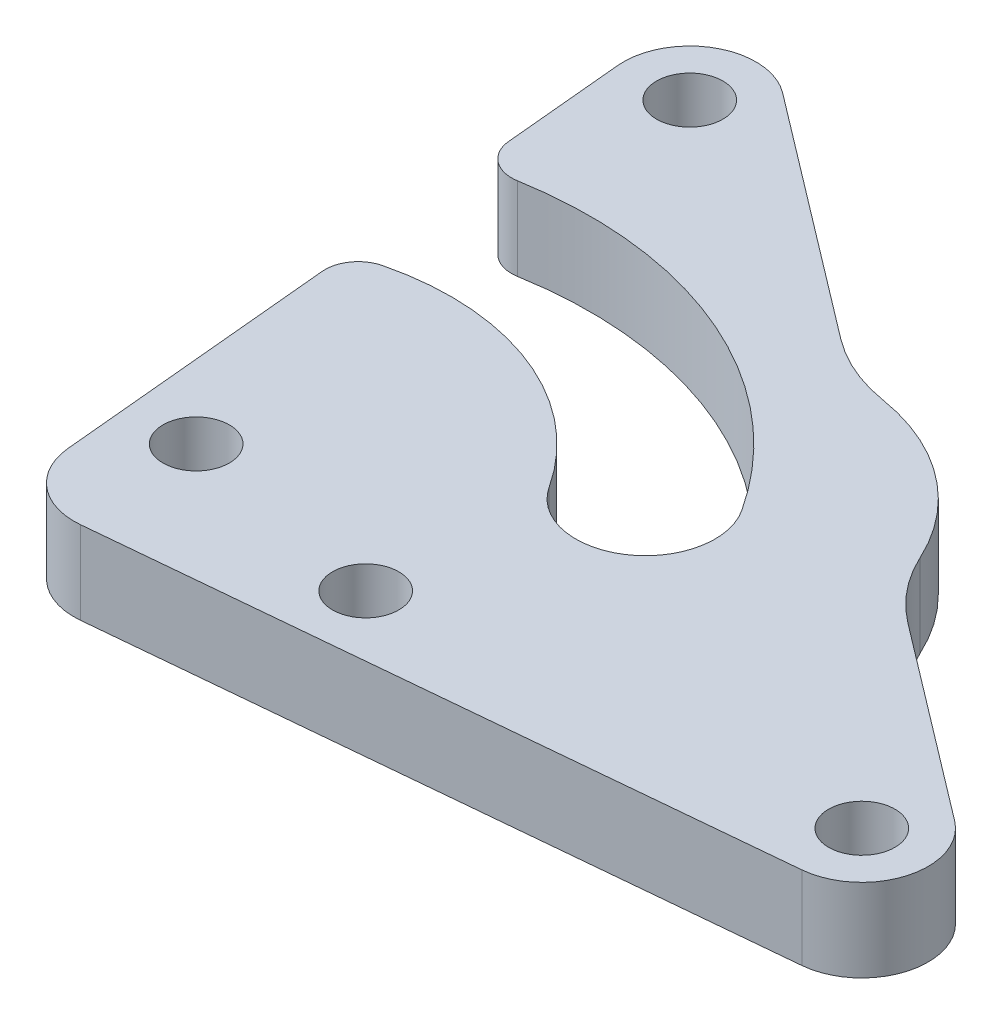
from build123d import *

# Parameters (mm, degrees)
SKETCH_1_R          = 2
EXTRUDE_1_DEPTH     = 5
EXTRUDE_2_DEPTH     = 5
CUT_EXTRUDE_1_DEPTH = 6
EXTRUDE_3_DEPTH     = 5
FILLET_1_R          = 10
FILLET_2_R          = 2
SKETCH_6_R          = 2
CUT_EXTRUDE_2_DEPTH = 6


with BuildPart() as part:
    # 草图1 → 凸台-拉伸1 (new body)
    with BuildSketch(Plane(origin=(0, 0, 0), x_dir=(1, 0, 0), z_dir=(0, 1, 0))):
        with BuildLine():
            ThreePointArc((-20.0875, 4), (-23.044826598, 2.693365811), (-24.070081176, -0.372890305))
            ThreePointArc((-24.070081176, -0.372890305), (-22.780865811, -2.957326598), (-20.0875, -4))
            ThreePointArc((-20.0875, -4), (-17.130173402, -2.693365811), (-16.104918824, 0.372890305))
            Line((-16.104918824, 0.372890305), (-16.444526225, 4))
            Line((-16.444526225, 4), (-20.0875, 4))
        make_face()
        with Locations((-20.0875, 0)):
            Circle(SKETCH_1_R, mode=Mode.SUBTRACT)
        with BuildLine():
            Line((-27.14754486, 32.495352138), (-24.070081176, -0.372890305))
            ThreePointArc((-24.070081176, -0.372890305), (-23.044826598, 2.693365811), (-20.0875, 4))
            Line((-20.0875, 4), (-16.444526225, 4))
            Line((-16.444526225, 4), (-18.333300994, 24.172685504))
            Line((-18.333300994, 24.172685504), (-25.585127327, 29.683464909))
            ThreePointArc((-25.585127327, 29.683464909), (-26.661456606, 30.925425609), (-27.14754486, 32.495352138))
        make_face()
        with BuildLine():
            ThreePointArc((-20.74480004, 36.053019976), (-25.107780517, 36.364735365), (-27.14754486, 32.495352138))
            ThreePointArc((-27.14754486, 32.495352138), (-26.661456606, 30.925425609), (-25.585127327, 29.683464909))
            Line((-25.585127327, 29.683464909), (-18.333300994, 24.172685504))
            Line((-18.333300994, 24.172685504), (-19.182382508, 33.241132747))
            ThreePointArc((-19.182382508, 33.241132747), (-19.668470762, 34.811059276), (-20.74480004, 36.053019976))
        make_face()
        with Locations((-23.164963684, 32.868242443)):
            Circle(SKETCH_1_R, mode=Mode.SUBTRACT)
        with BuildLine():
            Line((22.507663644, 3.184777534), (-20.74480004, 36.053019976))
            ThreePointArc((-20.74480004, 36.053019976), (-19.668470762, 34.811059276), (-19.182382508, 33.241132747))
            Line((-19.182382508, 33.241132747), (-18.333300994, 24.172685504))
            Line((-18.333300994, 24.172685504), (8.212637649, 4))
            Line((8.212637649, 4), (20.0875, 4))
            ThreePointArc((20.0875, 4), (21.364388771, 3.790719598), (22.507663644, 3.184777534))
        make_face()
        with BuildLine():
            ThreePointArc((-16.104918824, 0.372890305), (-17.130173402, -2.693365811), (-20.0875, -4))
            Line((-20.0875, -4), (20.0875, -4))
            ThreePointArc((20.0875, -4), (18.810611229, -3.790719598), (17.667336356, -3.184777534))
            Line((17.667336356, -3.184777534), (8.212637649, 4))
            Line((8.212637649, 4), (-16.444526225, 4))
            Line((-16.444526225, 4), (-16.104918824, 0.372890305))
        make_face()
        with BuildLine():
            ThreePointArc((17.667336356, -3.184777534), (18.810611229, -3.790719598), (20.0875, -4))
            ThreePointArc((20.0875, -4), (23.878219598, -1.276888771), (22.507663644, 3.184777534))
            ThreePointArc((22.507663644, 3.184777534), (21.364388771, 3.790719598), (20.0875, 4))
            Line((20.0875, 4), (8.212637649, 4))
            Line((8.212637649, 4), (17.667336356, -3.184777534))
        make_face()
        with Locations((20.0875, 0)):
            Circle(SKETCH_1_R, mode=Mode.SUBTRACT)
        Polygon((-18.333300994, 24.172685504), (-16.444526225, 4), (8.212637649, 4), align=None)
    extrude(amount=EXTRUDE_1_DEPTH)

    # 草图2 → 凸台-拉伸2 (add)
    with BuildSketch(Plane(origin=(0, 5, 0), x_dir=(1, 0, 0), z_dir=(0, 1, 0))):
        with BuildLine():
            ThreePointArc((-20.0875, -4), (-22.780865811, -2.957326598), (-24.070081176, -0.372890305))
            Line((-24.070081176, -0.372890305), (-23.720962628, -4.10158193))
            ThreePointArc((-23.720962628, -4.10158193), (-22.290826699, -6.808468121), (-19.365512753, -7.711274824))
            Line((-19.365512753, -7.711274824), (20.460368699, -3.982583199))
            ThreePointArc((20.460368699, -3.982583199), (20.274137625, -3.995643427), (20.0875, -4))
            Line((20.0875, -4), (-20.0875, -4))
        make_face()
    extrude(amount=-EXTRUDE_2_DEPTH)

    # 草图3 → 切除-拉伸1 (cut, through all)
    with BuildSketch(Plane(origin=(0, 5, 0), x_dir=(1, 0, 0), z_dir=(0, 1, 0))):
        with BuildLine():
            ThreePointArc((-36.289327432, 17.433897667), (-37.629570165, 14.285674695), (-36.182704661, 11.185007239))
            ThreePointArc((-36.182704661, 11.185007239), (-31.653466249, 15.823666602), (-25.858788976, 18.731049718))
            Line((-25.858788976, 18.731049718), (-26.257218708, 22.986399698))
            ThreePointArc((-26.257218708, 22.986399698), (-31.612650276, 20.82332613), (-36.289327432, 17.433897667))
        make_face()
        with BuildLine():
            ThreePointArc((-25.858788976, 18.731049718), (-11.47348363, 17.605644606), (-1.756724615, 6.938492183))
            ThreePointArc((-1.756724615, 6.938492183), (0.40025314, 9.594618202), (-0.134776474, 12.974159854))
            ThreePointArc((-0.134776474, 12.974159854), (-11.569633945, 22.223545124), (-26.257218708, 22.986399698))
            Line((-26.257218708, 22.986399698), (-25.858788976, 18.731049718))
        make_face()
        with BuildLine():
            ThreePointArc((-7.176914189, 8.395044611), (-4.745829362, 6.62850376), (-1.756724615, 6.938492183))
            ThreePointArc((-1.756724615, 6.938492183), (-11.47348363, 17.605644606), (-25.858788976, 18.731049718))
            Line((-25.858788976, 18.731049718), (-25.456435977, 14.433798061))
            ThreePointArc((-25.456435977, 14.433798061), (-15.256790284, 14.622730376), (-7.176914189, 8.395044611))
        make_face()
        with BuildLine():
            ThreePointArc((-25.858788976, 18.731049718), (-31.653466249, 15.823666602), (-36.182704661, 11.185007239))
            ThreePointArc((-36.182704661, 11.185007239), (-33.358528619, 10.15793874), (-30.571035397, 11.280757314))
            ThreePointArc((-30.571035397, 11.280757314), (-28.168999159, 13.109133127), (-25.456435977, 14.433798061))
            Line((-25.456435977, 14.433798061), (-25.858788976, 18.731049718))
        make_face()
    extrude(amount=-CUT_EXTRUDE_1_DEPTH, mode=Mode.SUBTRACT)

    # 草图4 → 凸台-拉伸3 (add)
    with BuildSketch(Plane(origin=(0, 5, 0), x_dir=(1, 0, 0), z_dir=(0, 1, 0))):
        with BuildLine():
            Line((-3.809557715, 23.183657097), (8.427670456, 13.884390694))
            ThreePointArc((8.427670456, 13.884390694), (3.907166054, 20.637032025), (-3.809557715, 23.183657097))
        make_face()
    extrude(amount=-EXTRUDE_3_DEPTH)

    # 圆角1
    fillet_1_edges = [part.edges().sort_by_distance(p)[0] for p in [
        (8.427670456, 2.5, -13.884390694),
        (-3.809557715, 2.5, -23.183657097),
    ]]
    fillet(fillet_1_edges, radius=FILLET_1_R)

    # 圆角2
    fillet_2_edges = [part.edges().sort_by_distance(p)[0] for p in [
        (-26.257218708, 2.5, -22.986399698),
        (-25.456435977, 2.5, -14.433798061),
    ]]
    fillet(fillet_2_edges, radius=FILLET_2_R)

    # 草图6 → 切除-拉伸2 (cut, through all)
    with BuildSketch(Plane(origin=(0, 5, 0), x_dir=(1, 0, 0), z_dir=(0, 1, 0))):
        with Locations((-7.292808957, -2.56347694)):
            Circle(SKETCH_6_R)
    extrude(amount=-CUT_EXTRUDE_2_DEPTH, mode=Mode.SUBTRACT)


solid = part.part
